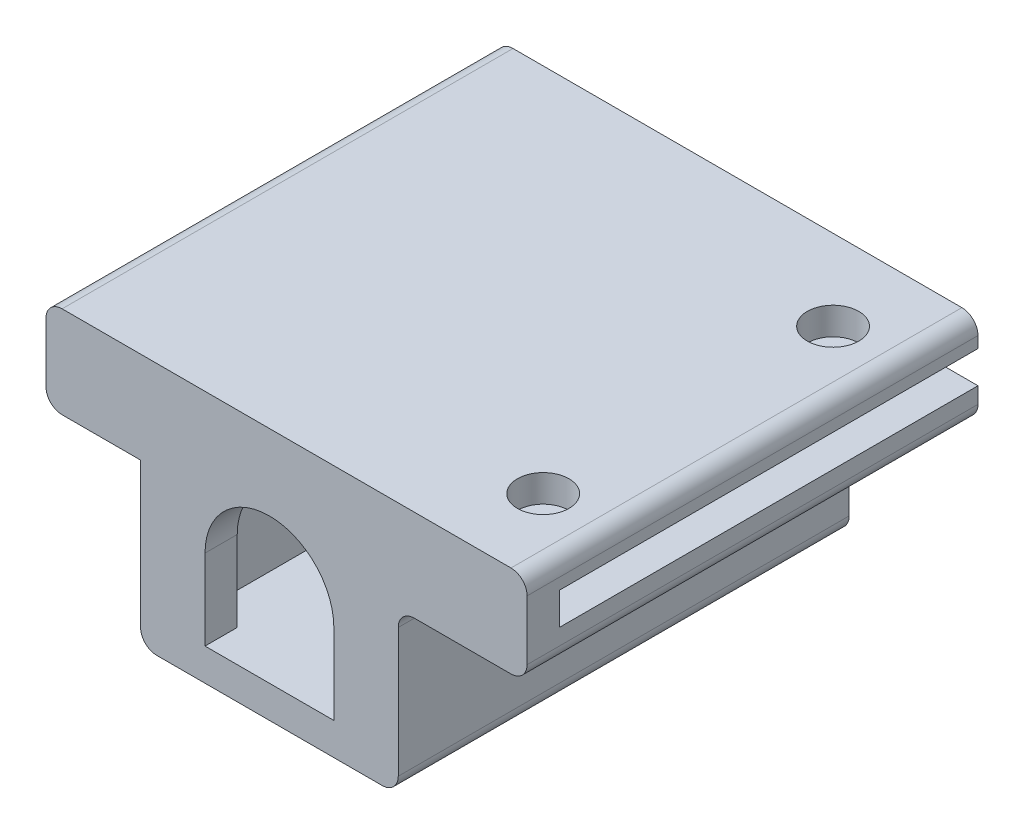
from build123d import *

# Parameters (mm, degrees)
EXTRUDE_1_DEPTH          = 2
EXTRUDE_2_DEPTH          = 26
SKETCH_6_W               = 12
SKETCH_6_H               = 1
EXTRUDE_3_DEPTH          = 1.6
CUT_EXTRUDE_1_DEPTH      = 11
CUT_EXTRUDE_1_DEPTH_BACK = 1
SKETCH_5_R               = 1.6
CUT_EXTRUDE_2_DEPTH      = 5.7


with BuildPart() as part:
    # 草图1 → 凸台-拉伸1 (new body)
    with BuildSketch(Plane.XY):
        with BuildLine():
            ThreePointArc((8, 2), (8.292893219, 2.707106781), (9, 3))
            Line((9, 3), (15, 3))
            ThreePointArc((15, 3), (15.707106781, 3.292893219), (16, 4))
            Line((16, 4), (16, 7.7))
            ThreePointArc((16, 7.7), (15.707106781, 8.407106781), (15, 8.7))
            Line((15, 8.7), (-12.875, 8.7))
            ThreePointArc((-12.875, 8.7), (-13.582106781, 8.407106781), (-13.875, 7.7))
            Line((-13.875, 7.7), (-13.875, 4))
            ThreePointArc((-13.875, 4), (-13.582106781, 3.292893219), (-12.875, 3))
            Line((-12.875, 3), (-8, 3))
            Line((-8, 3), (-8, -6))
            ThreePointArc((-8, -6), (-7.707106781, -6.707106781), (-7, -7))
            Line((-7, -7), (7, -7))
            ThreePointArc((7, -7), (7.707106781, -6.707106781), (8, -6))
            Line((8, -6), (8, 2))
        make_face()
        with BuildLine():
            Line((4, -5), (-4, -5))
            Line((-4, -5), (-4, 0))
            ThreePointArc((-4, 0), (0, 4), (4, 0))
            Line((4, 0), (4, -5))
        make_face(mode=Mode.SUBTRACT)
    extrude(amount=EXTRUDE_1_DEPTH)

    # 草图2 → 凸台-拉伸2 (add)
    with BuildSketch(Plane(origin=(0, 0, 0), x_dir=(-1, 0, 0), z_dir=(0, 0, -1))):
        with BuildLine():
            Line((6, -4), (6, -5))
            Line((6, -5), (5, -5))
            Line((5, -5), (-5, -5))
            Line((-5, -5), (-6, -5))
            Line((-6, -5), (-6, -4))
            Line((-6, -4), (-6, 4))
            Line((-6, 4), (-6, 5))
            Line((-6, 5), (-16, 5))
            Line((-16, 5), (-16, 4))
            ThreePointArc((-16, 4), (-15.707106781, 3.292893219), (-15, 3))
            Line((-15, 3), (-9, 3))
            ThreePointArc((-9, 3), (-8.292893219, 2.707106781), (-8, 2))
            Line((-8, 2), (-8, -6))
            ThreePointArc((-8, -6), (-7.707106781, -6.707106781), (-7, -7))
            Line((-7, -7), (7, -7))
            ThreePointArc((7, -7), (7.707106781, -6.707106781), (8, -6))
            Line((8, -6), (8, 3))
            Line((8, 3), (12.875, 3))
            ThreePointArc((12.875, 3), (13.582106781, 3.292893219), (13.875, 4))
            Line((13.875, 4), (13.875, 7.7))
            ThreePointArc((13.875, 7.7), (13.582106781, 8.407106781), (12.875, 8.7))
            Line((12.875, 8.7), (-15, 8.7))
            ThreePointArc((-15, 8.7), (-15.707106781, 8.407106781), (-16, 7.7))
            Line((-16, 7.7), (-16, 7))
            Line((-16, 7), (11.875, 7))
            Line((11.875, 7), (11.875, 5))
            Line((11.875, 5), (6, 5))
            Line((6, 5), (6, 4))
            Line((6, 4), (6, -4))
        make_face()
    extrude(amount=EXTRUDE_2_DEPTH)

    # 草图6 → 凸台-拉伸3 (add)
    with BuildSketch(Plane(origin=(0, 0, -26), x_dir=(-1, 0, 0), z_dir=(0, 0, -1))):
        with Locations((0, -4.5)):
            Rectangle(SKETCH_6_W, SKETCH_6_H)
    extrude(amount=-EXTRUDE_3_DEPTH)

    # 草图4 → 切除-拉伸1 (cut, two sides)
    with BuildSketch(Plane.XZ.offset(-3)) as cut_extrude_1_sk:
        Polygon((15, -19.267949192), (12, -17.535898385), (9, -19.267949192), (9, -22.732050808), (12, -24.464101615), (15, -22.732050808), align=None)
        Polygon((9, -1.267949192), (9, -4.732050808), (12, -6.464101615), (15, -4.732050808), (15, -1.267949192), (12, 0.464101615), align=None)
    extrude(amount=CUT_EXTRUDE_1_DEPTH, mode=Mode.SUBTRACT)
    extrude(cut_extrude_1_sk.sketch, amount=-CUT_EXTRUDE_1_DEPTH_BACK, mode=Mode.SUBTRACT)

    # 草图5 → 切除-拉伸2 (cut, through all)
    with BuildSketch(Plane.XZ.offset(-4)):
        with Locations((12, -21)):
            Circle(SKETCH_5_R)
        with Locations((12, -3)):
            Circle(SKETCH_5_R)
    extrude(amount=-CUT_EXTRUDE_2_DEPTH, mode=Mode.SUBTRACT)


solid = part.part
